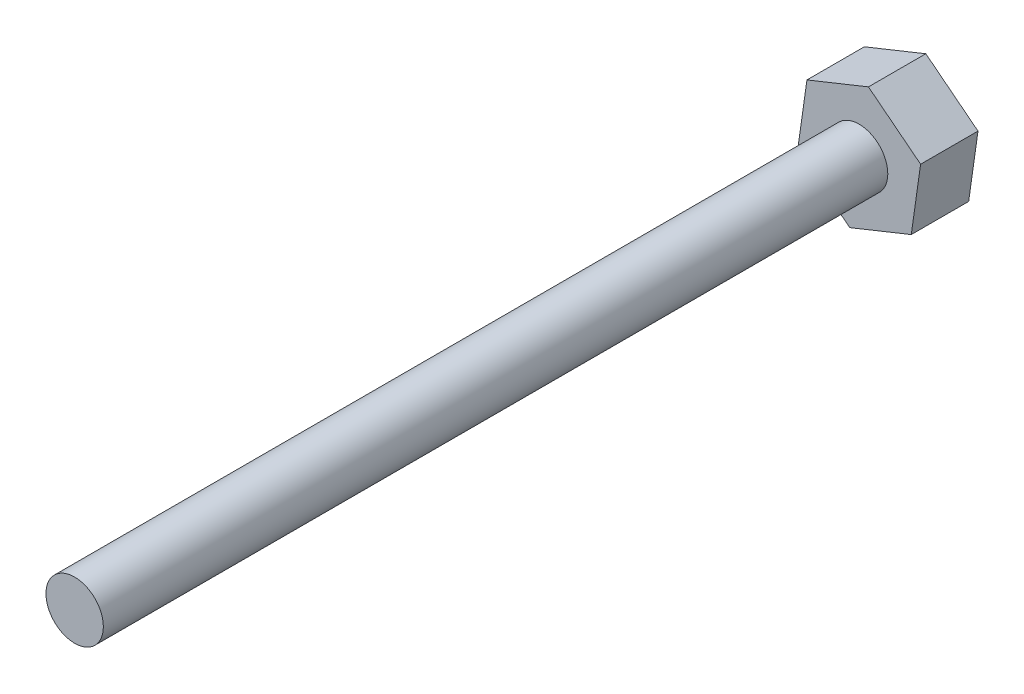
from build123d import *

# Parameters (mm, degrees)
BOSS_EXTRUDE1_DEPTH = 3
SKETCH3_R           = 1.5
BOSS_EXTRUDE2_DEPTH = 41


with BuildPart() as part:
    # Sketch1 → Boss-Extrude1 (new body)
    with BuildSketch(Plane.XY):
        Polygon((-2.726035123, 2.137459358), (-3.214111665, -1.292085989), (-0.488076542, -3.429545347), (2.726035123, -2.137459358), (3.214111665, 1.292085989), (0.488076542, 3.429545347), align=None)
    extrude(amount=BOSS_EXTRUDE1_DEPTH)

    # Sketch3 → Boss-Extrude2 (add)
    with BuildSketch(Plane.XY.offset(3)):
        Circle(SKETCH3_R)
    extrude(amount=BOSS_EXTRUDE2_DEPTH)


solid = part.part
